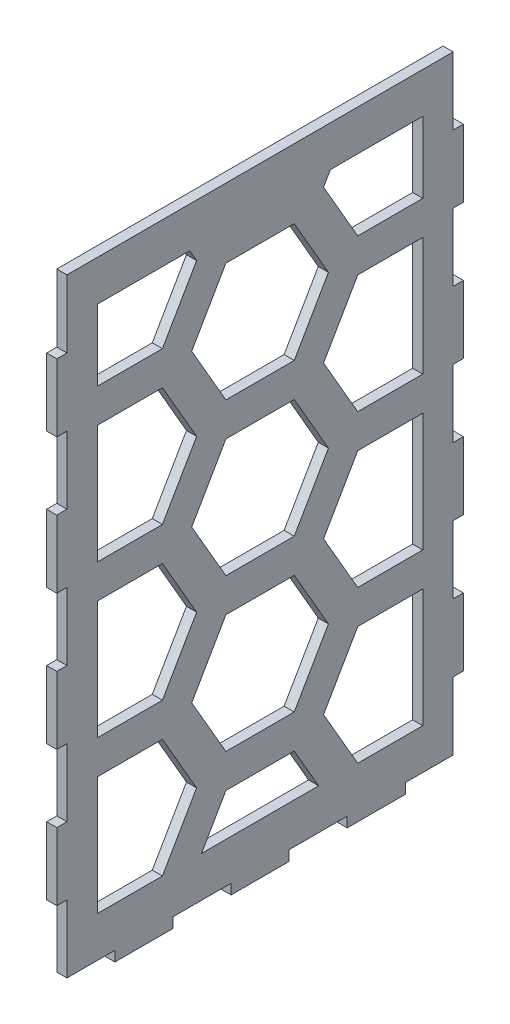
from build123d import *

# Parameters (mm, degrees)
SKETCH1_W           = 114.1727
SKETCH1_H           = 180
BOSS_EXTRUDE1_DEPTH = 3
SKETCH2_W           = 17.167528572
SKETCH2_H           = 3
SKETCH2_W_2         = 3
SKETCH2_H_2         = 20
BOSS_EXTRUDE2_DEPTH = 3
CUT_EXTRUDE1_DEPTH  = 10


with BuildPart() as part:
    # Sketch1 → Boss-Extrude1 (new body)
    with BuildSketch(Plane(origin=(0, 0, 0), x_dir=(0, 0, -1), z_dir=(1, 0, 0))):
        Rectangle(SKETCH1_W, SKETCH1_H)
    extrude(amount=BOSS_EXTRUDE1_DEPTH)

    # Sketch2 → Boss-Extrude2 (add)
    with BuildSketch(Plane(origin=(3, 0, 0), x_dir=(0, 0, -1), z_dir=(1, 0, 0))):
        with Locations((-34.335057143, -91.5)):
            Rectangle(SKETCH2_W, SKETCH2_H)
        with Locations((0, -91.5)):
            Rectangle(SKETCH2_W, SKETCH2_H)
        with Locations((34.335057143, -91.5)):
            Rectangle(SKETCH2_W, SKETCH2_H)
        with Locations((58.58635, -60)):
            Rectangle(SKETCH2_W_2, SKETCH2_H_2)
        with Locations((58.58635, -20)):
            Rectangle(SKETCH2_W_2, SKETCH2_H_2)
        with Locations((58.58635, 20)):
            Rectangle(SKETCH2_W_2, SKETCH2_H_2)
        with Locations((58.58635, 60)):
            Rectangle(SKETCH2_W_2, SKETCH2_H_2)
        with Locations((-58.58635, -60)):
            Rectangle(SKETCH2_W_2, SKETCH2_H_2)
        with Locations((-58.58635, -20)):
            Rectangle(SKETCH2_W_2, SKETCH2_H_2)
        with Locations((-58.58635, 20)):
            Rectangle(SKETCH2_W_2, SKETCH2_H_2)
        with Locations((-58.58635, 60)):
            Rectangle(SKETCH2_W_2, SKETCH2_H_2)
    extrude(amount=-BOSS_EXTRUDE2_DEPTH)

    # Sketch3 → Cut-Extrude1 (cut)
    with BuildSketch(Plane(origin=(0, 0, -3), x_dir=(0, 0, 1), z_dir=(-1, 0, 0))):
        Polygon((-25.867513459, -43), (-45.08635, -43), (-45.08635, -78), (-25.867513459, -78), (-15.763883749, -60.5), align=None)
        Polygon((-7.103629711, -65.5), (-14.320508076, -78), (20.320508076, -78), (13.103629711, -65.5), align=None)
        Polygon((21.763883749, -60.5), (31.867513459, -78), (51.08635, -78), (51.08635, -43), (31.867513459, -43), align=None)
        Polygon((23.207259422, -38), (13.103629711, -20.5), (-7.103629711, -20.5), (-17.207259422, -38), (-7.103629711, -55.5), (13.103629711, -55.5), align=None)
        Polygon((-45.08635, 2), (-45.08635, -33), (-25.867513459, -33), (-15.763883749, -15.5), (-25.867513459, 2), align=None)
        Polygon((23.207259422, 7), (13.103629711, 24.5), (-7.103629711, 24.5), (-17.207259422, 7), (-7.103629711, -10.5), (13.103629711, -10.5), align=None)
        Polygon((31.867513459, -33), (51.08635, -33), (51.08635, 2), (31.867513459, 2), (21.763883749, -15.5), align=None)
        Polygon((51.08635, 12), (51.08635, 47), (31.867513459, 47), (21.763883749, 29.5), (31.867513459, 12), align=None)
        Polygon((-45.08635, 47), (-45.08635, 12), (-25.867513459, 12), (-15.763883749, 29.5), (-25.867513459, 47), align=None)
        Polygon((23.207259422, 52), (13.103629711, 69.5), (-7.103629711, 69.5), (-17.207259422, 52), (-7.103629711, 34.5), (13.103629711, 34.5), align=None)
        Polygon((-45.08635, 78), (-45.08635, 57), (-25.867513459, 57), (-15.763883749, 74.5), (-17.784609691, 78), align=None)
        Polygon((51.08635, 78), (23.784609691, 78), (21.763883749, 74.5), (31.867513459, 57), (51.08635, 57), align=None)
    extrude(amount=-CUT_EXTRUDE1_DEPTH, mode=Mode.SUBTRACT)


solid = part.part
